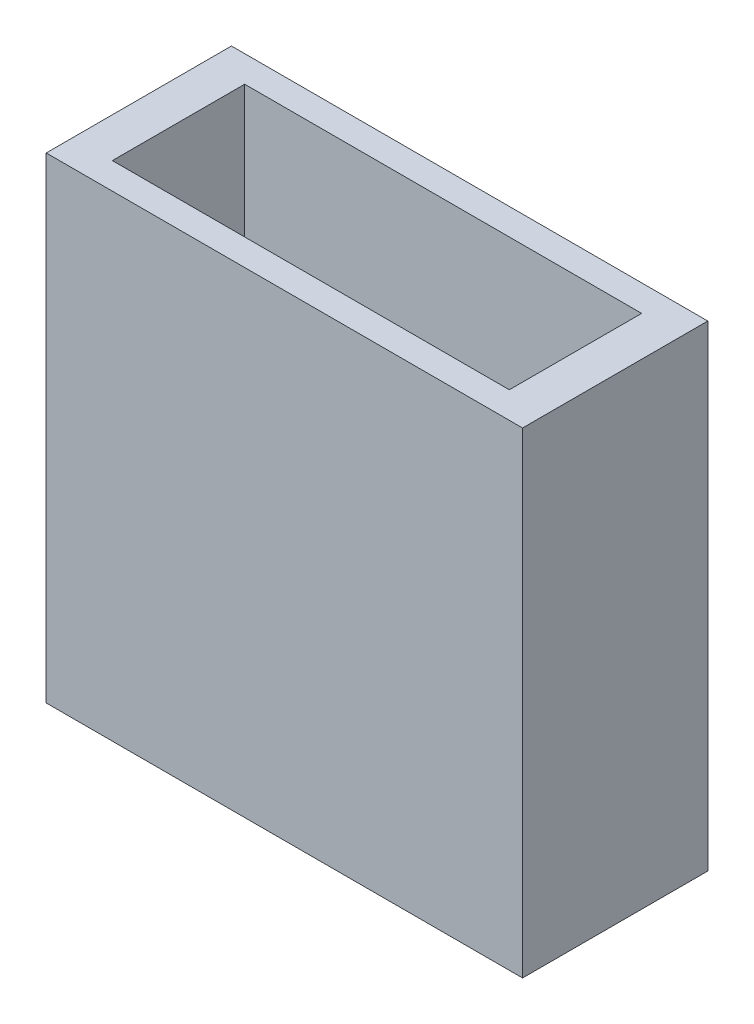
from build123d import *

# Parameters (mm, degrees)
SKETCH1_W               = 45.72
SKETCH1_H               = 17.78
BOSS_EXTRUDE1_DEPTH     = 45.72
SKETCH2_W               = 38.1
SKETCH2_H               = 12.7
CUT_EXTRUDE1_DEPTH      = 41.91
SKETCH6_R               = 3.048
CUT_EXTRUDE2_DEPTH      = 1.512975339
CUT_EXTRUDE2_DEPTH_BACK = 15.24


with BuildPart() as part:
    # Sketch1 → Boss-Extrude1 (new body)
    with BuildSketch(Plane(origin=(0, 0, 0), x_dir=(1, 0, 0), z_dir=(0, 1, 0))):
        with Locations((22.86, 8.89)):
            Rectangle(SKETCH1_W, SKETCH1_H)
    extrude(amount=BOSS_EXTRUDE1_DEPTH)

    # Sketch2 → Cut-Extrude1 (cut)
    with BuildSketch(Plane(origin=(0, 45.72, 0), x_dir=(1, 0, 0), z_dir=(0, 1, 0))):
        with Locations((22.86, 8.89)):
            Rectangle(SKETCH2_W, SKETCH2_H)
    extrude(amount=-CUT_EXTRUDE1_DEPTH, mode=Mode.SUBTRACT)

    # Sketch6 → Cut-Extrude2 (cut, two sides)
    with BuildSketch(Plane(origin=(0, 0, 0), x_dir=(-0.983268965, 0.18208123, 0.005344962), z_dir=(-0.182159664, -0.982845594, -0.028851256))) as cut_extrude2_sk:
        with Locations((-22.14222649, 8.882344385)):
            Circle(SKETCH6_R)
        with Locations((-15.03022649, 8.882344385)):
            Circle(SKETCH6_R)
        with Locations((-29.25422649, 8.882344385)):
            Circle(SKETCH6_R)
    extrude(amount=CUT_EXTRUDE2_DEPTH, mode=Mode.SUBTRACT)
    extrude(cut_extrude2_sk.sketch, amount=-CUT_EXTRUDE2_DEPTH_BACK, mode=Mode.SUBTRACT)


solid = part.part
